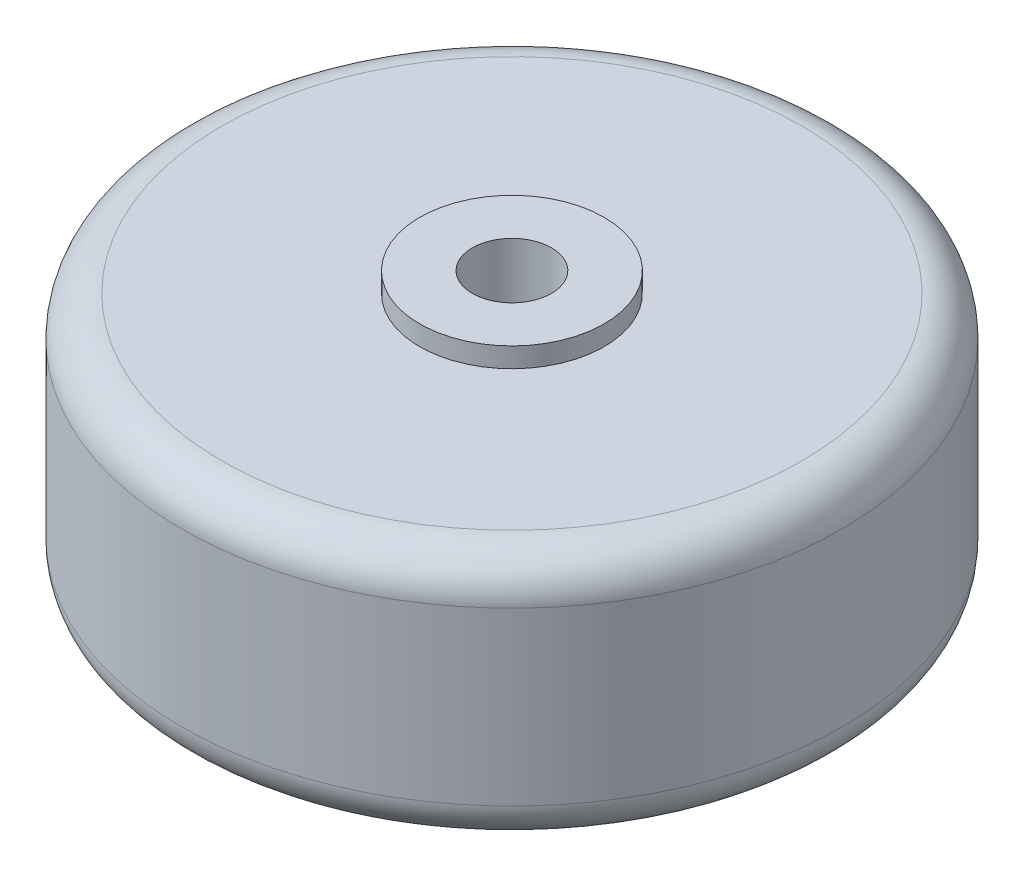
from build123d import *


with BuildPart() as part:
    # Sketch2 → Revolve2 (revolve)
    with BuildSketch(Plane.XY):
        with BuildLine():
            Line((3, -11), (3, 11))
            Line((3, 11), (7, 11))
            Line((7, 11), (7, 9.5))
            Line((7, 9.5), (22, 9.5))
            ThreePointArc((22, 9.5), (24.121320344, 8.621320344), (25, 6.5))
            Line((25, 6.5), (25, -6.5))
            ThreePointArc((25, -6.5), (24.121320344, -8.621320344), (22, -9.5))
            Line((22, -9.5), (7, -9.5))
            Line((7, -9.5), (7, -11))
            Line((7, -11), (3, -11))
        make_face()
    revolve(axis=Axis((0, 0, 0), (0, 1, 0)))


solid = part.part
